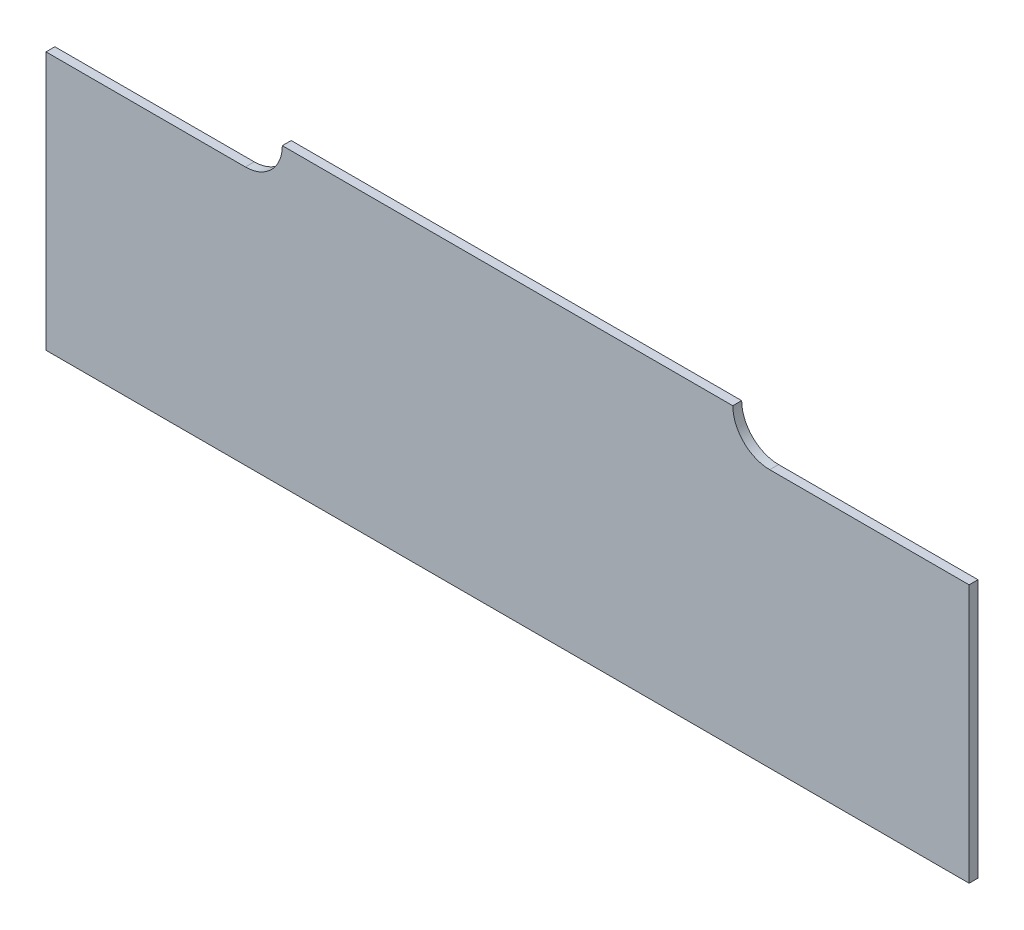
from build123d import *

# Parameters (mm, degrees)
SKETCH1_W           = 12.5
SKETCH1_H           = 3.5
BOSS_EXTRUDE1_DEPTH = 0.12


with BuildPart() as part:
    # Sketch1 → Boss-Extrude1 (new body)
    with BuildSketch(Plane.XY.offset(0.12)):
        with Locations((6.25, 1.75)):
            Rectangle(SKETCH1_W, SKETCH1_H)
        with BuildLine():
            ThreePointArc((3.2, 4), (3.053553391, 3.646446609), (2.7, 3.5))
            Line((2.7, 3.5), (9.8, 3.5))
            ThreePointArc((9.8, 3.5), (9.446446609, 3.646446609), (9.3, 4))
            Line((9.3, 4), (3.2, 4))
        make_face()
    extrude(amount=-BOSS_EXTRUDE1_DEPTH)


solid = part.part
